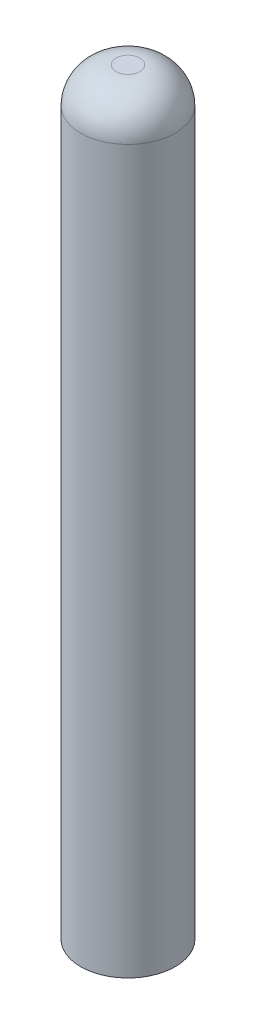
from build123d import *

# Parameters (mm, degrees)
SKETCH1_R      = 3.175
EXTRUDE1_DEPTH = 25.4
FILLET1_R      = 2.38125


with BuildPart() as part:
    # Sketch1 → Extrude1 (new body, symmetric)
    with BuildSketch(Plane(origin=(0, 0, 0), x_dir=(1, 0, 0), z_dir=(0, 1, 0))):
        Circle(SKETCH1_R)
    extrude(amount=EXTRUDE1_DEPTH, both=True)

    # Fillet1
    fillet1_edges = [part.edges().sort_by_distance(p)[0] for p in [
        (-3.175, 25.4, 0),
    ]]
    fillet(fillet1_edges, radius=FILLET1_R)


solid = part.part
